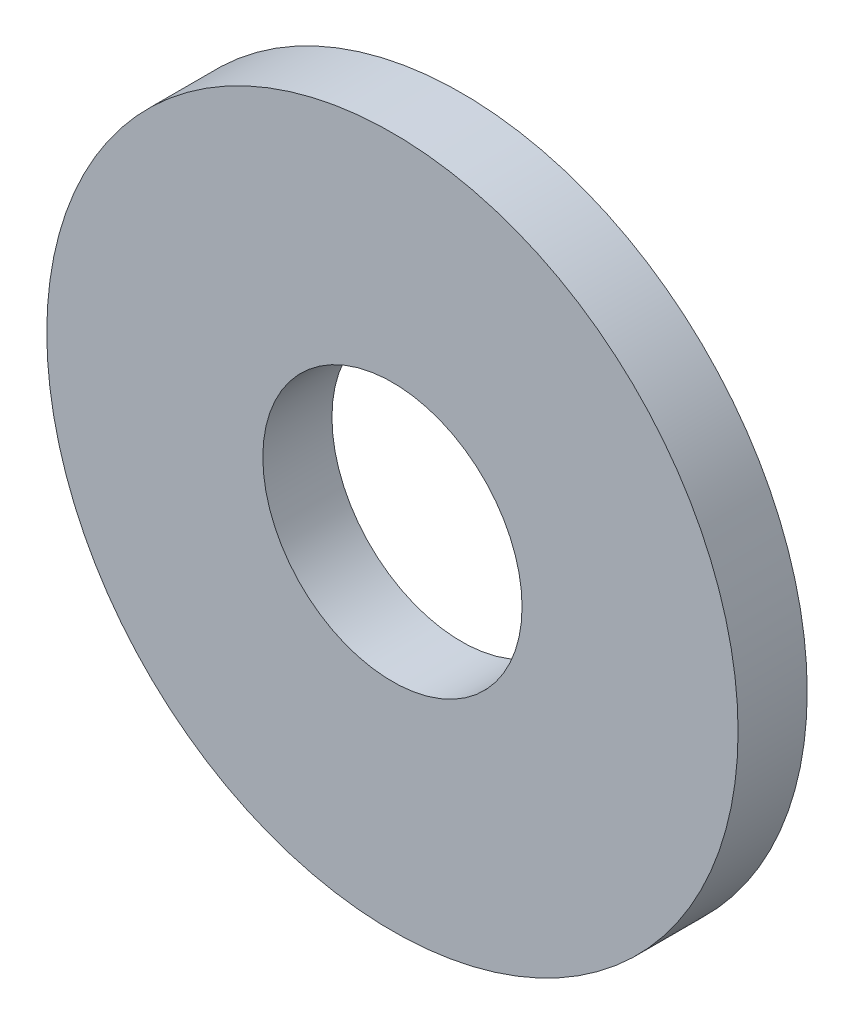
from build123d import *

# Parameters (mm, degrees)
SKETCH_2_R      = 4
SKETCH_2_R_2    = 1.5
EXTRUDE_1_DEPTH = 0.8


with BuildPart() as part:
    # 草图2 → 凸台-拉伸1 (new body)
    with BuildSketch(Plane.XY):
        Circle(SKETCH_2_R)
        Circle(SKETCH_2_R_2, mode=Mode.SUBTRACT)
    extrude(amount=EXTRUDE_1_DEPTH)


solid = part.part
